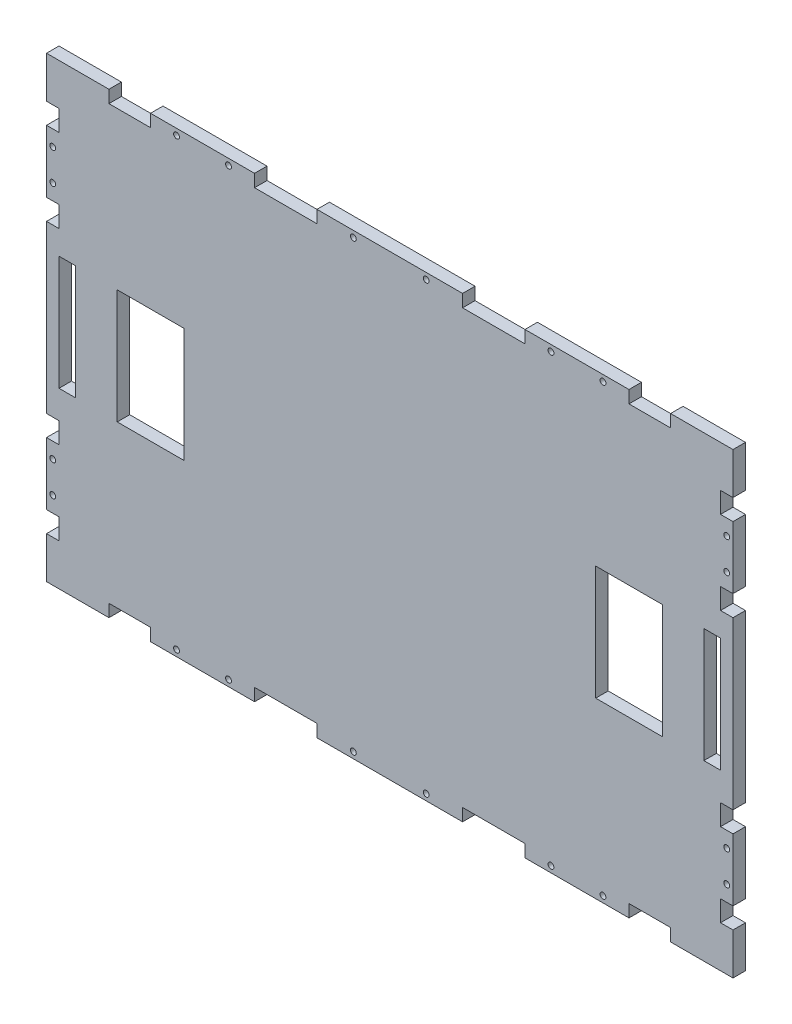
from build123d import *

# Parameters (mm, degrees)
ESQUISSE1_W             = 330
ESQUISSE1_H             = 220
BOSS_EXTRU_1_DEPTH      = 6
ESQUISSE2_W             = 8
ESQUISSE2_H             = 55
ESQUISSE2_W_2           = 32
ENL_V_MAT_EXTRU_1_DEPTH = 6
ESQUISSE3_W             = 20
ESQUISSE3_H             = 6
ESQUISSE3_W_2           = 30
ESQUISSE3_W_3           = 6
ESQUISSE3_H_2           = 10
ENL_V_MAT_EXTRU_2_DEPTH = 6
ESQUISSE4_R             = 1.4
ENL_V_MAT_EXTRU_3_DEPTH = 6


with BuildPart() as part:
    # Esquisse1 → Boss.-Extru.1 (new body)
    with BuildSketch(Plane.XY):
        Rectangle(ESQUISSE1_W, ESQUISSE1_H)
    extrude(amount=BOSS_EXTRU_1_DEPTH)

    # Esquisse2 → Enlèv. mat.-Extru.1 (cut)
    with BuildSketch(Plane.XY.offset(6)):
        with Locations((-155, 1)):
            Rectangle(ESQUISSE2_W, ESQUISSE2_H)
        with Locations((-115, 1)):
            Rectangle(ESQUISSE2_W_2, ESQUISSE2_H)
        with Locations((115, 1)):
            Rectangle(ESQUISSE2_W_2, ESQUISSE2_H)
        with Locations((155, 1)):
            Rectangle(ESQUISSE2_W, ESQUISSE2_H)
    extrude(amount=-ENL_V_MAT_EXTRU_1_DEPTH, mode=Mode.SUBTRACT)

    # Esquisse3 → Enlèv. mat.-Extru.2 (cut)
    with BuildSketch(Plane.XY.offset(6)):
        with Locations((-125, 107)):
            Rectangle(ESQUISSE3_W, ESQUISSE3_H)
        with Locations((-50, 107)):
            Rectangle(ESQUISSE3_W_2, ESQUISSE3_H)
        with Locations((-162, 45)):
            Rectangle(ESQUISSE3_W_3, ESQUISSE3_H_2)
        with Locations((50, 107)):
            Rectangle(ESQUISSE3_W_2, ESQUISSE3_H)
        with Locations((-162, 85)):
            Rectangle(ESQUISSE3_W_3, ESQUISSE3_H_2)
        with Locations((162, 85)):
            Rectangle(ESQUISSE3_W_3, ESQUISSE3_H_2)
        with Locations((162, 45)):
            Rectangle(ESQUISSE3_W_3, ESQUISSE3_H_2)
        with Locations((125, 107)):
            Rectangle(ESQUISSE3_W, ESQUISSE3_H)
        with Locations((125, -107)):
            Rectangle(ESQUISSE3_W, ESQUISSE3_H)
        with Locations((50, -107)):
            Rectangle(ESQUISSE3_W_2, ESQUISSE3_H)
        with Locations((162, -45)):
            Rectangle(ESQUISSE3_W_3, ESQUISSE3_H_2)
        with Locations((162, -85)):
            Rectangle(ESQUISSE3_W_3, ESQUISSE3_H_2)
        with Locations((-162, -85)):
            Rectangle(ESQUISSE3_W_3, ESQUISSE3_H_2)
        with Locations((-162, -45)):
            Rectangle(ESQUISSE3_W_3, ESQUISSE3_H_2)
        with Locations((-50, -107)):
            Rectangle(ESQUISSE3_W_2, ESQUISSE3_H)
        with Locations((-125, -107)):
            Rectangle(ESQUISSE3_W, ESQUISSE3_H)
    extrude(amount=-ENL_V_MAT_EXTRU_2_DEPTH, mode=Mode.SUBTRACT)

    # Esquisse4 → Enlèv. mat.-Extru.3 (cut)
    with BuildSketch(Plane.XY.offset(6)):
        with Locations((-102.5, 107)):
            Circle(ESQUISSE4_R)
        with Locations((-77.5, 107)):
            Circle(ESQUISSE4_R)
        with Locations((-17.5, 107)):
            Circle(ESQUISSE4_R)
        with Locations((-162, 72.5)):
            Circle(ESQUISSE4_R)
        with Locations((-162, 57.5)):
            Circle(ESQUISSE4_R)
        with Locations((162, 57.5)):
            Circle(ESQUISSE4_R)
        with Locations((162, 72.5)):
            Circle(ESQUISSE4_R)
        with Locations((17.5, 107)):
            Circle(ESQUISSE4_R)
        with Locations((77.5, 107)):
            Circle(ESQUISSE4_R)
        with Locations((102.5, 107)):
            Circle(ESQUISSE4_R)
        with Locations((102.5, -107)):
            Circle(ESQUISSE4_R)
        with Locations((77.5, -107)):
            Circle(ESQUISSE4_R)
        with Locations((17.5, -107)):
            Circle(ESQUISSE4_R)
        with Locations((162, -72.5)):
            Circle(ESQUISSE4_R)
        with Locations((162, -57.5)):
            Circle(ESQUISSE4_R)
        with Locations((-162, -57.5)):
            Circle(ESQUISSE4_R)
        with Locations((-162, -72.5)):
            Circle(ESQUISSE4_R)
        with Locations((-17.5, -107)):
            Circle(ESQUISSE4_R)
        with Locations((-77.5, -107)):
            Circle(ESQUISSE4_R)
        with Locations((-102.5, -107)):
            Circle(ESQUISSE4_R)
    extrude(amount=-ENL_V_MAT_EXTRU_3_DEPTH, mode=Mode.SUBTRACT)


solid = part.part
